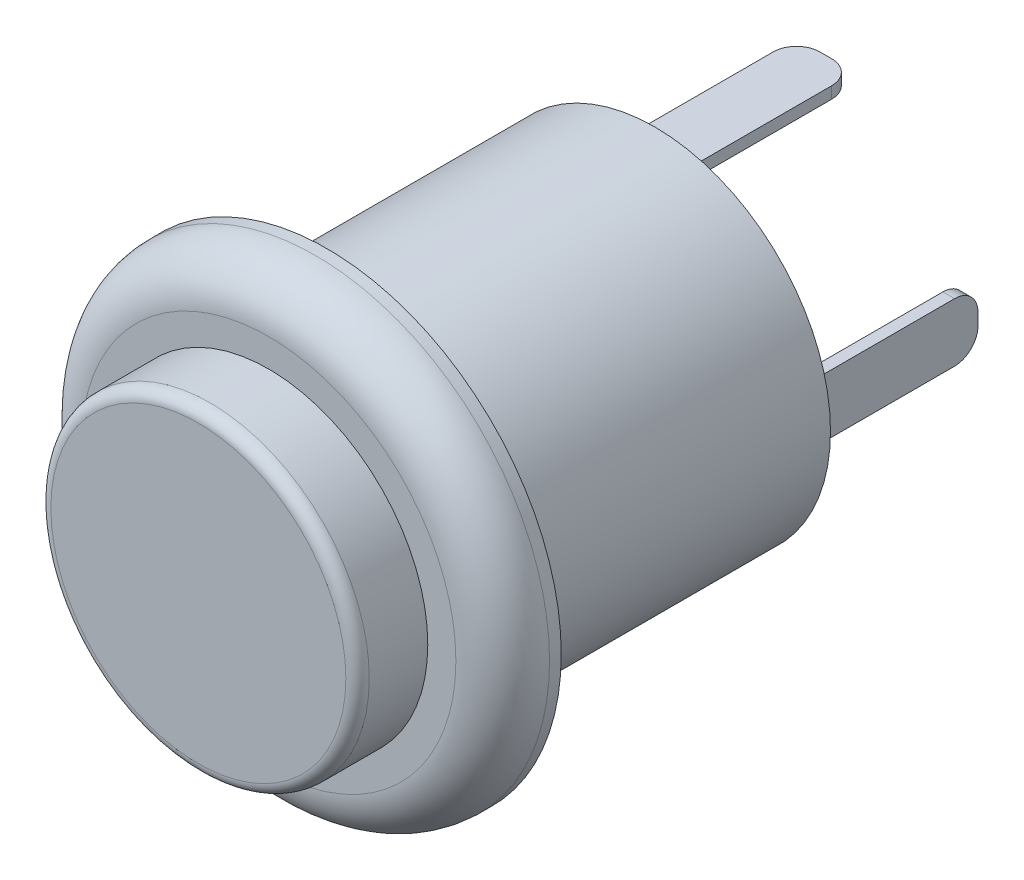
from build123d import *

# Parameters (mm, degrees)
SKETCH_1_R      = 7.5
EXTRUDE_1_DEPTH = 14
SKETCH_2_R      = 10
EXTRUDE_2_DEPTH = 2.5
SKETCH_3_R      = 6.8
EXTRUDE_3_DEPTH = 3
SKETCH_4_W      = 0.5
SKETCH_4_H      = 2.5
SKETCH_4_W_2    = 2.5
SKETCH_4_H_2    = 0.5
EXTRUDE_4_DEPTH = 7.3
FILLET_1_R      = 1
FILLET_2_R      = 0.5
FILLET_3_R      = 2


with BuildPart() as part:
    # ｽｹｯﾁ1 → ﾎﾞｽ - 押し出し1 (new body)
    with BuildSketch(Plane.XY):
        Circle(SKETCH_1_R)
    extrude(amount=EXTRUDE_1_DEPTH)

    # ｽｹｯﾁ2 → ﾎﾞｽ - 押し出し2 (add)
    with BuildSketch(Plane.XY.offset(14)):
        Circle(SKETCH_2_R)
    extrude(amount=EXTRUDE_2_DEPTH)

    # ｽｹｯﾁ3 → ﾎﾞｽ - 押し出し3 (add)
    with BuildSketch(Plane.XY.offset(16.5)):
        Circle(SKETCH_3_R)
    extrude(amount=EXTRUDE_3_DEPTH)

    # ｽｹｯﾁ4 → ﾎﾞｽ - 押し出し4 (add)
    with BuildSketch(Plane(origin=(0, 0, 0), x_dir=(-1, 0, 0), z_dir=(0, 0, -1))):
        with Locations((-6.25, 0)):
            Rectangle(SKETCH_4_W, SKETCH_4_H)
        with Locations((6.25, 0)):
            Rectangle(SKETCH_4_W, SKETCH_4_H)
        with Locations((0, 6.25)):
            Rectangle(SKETCH_4_W_2, SKETCH_4_H_2)
        with Locations((0, -6.25)):
            Rectangle(SKETCH_4_W_2, SKETCH_4_H_2)
    extrude(amount=EXTRUDE_4_DEPTH)

    # ﾌｨﾚｯﾄ1
    fillet_1_edges = [part.edges().sort_by_distance(p)[0] for p in [
        (6.25, 1.25, -7.3),
        (6.25, -1.25, -7.3),
        (-6.25, -1.25, -7.3),
        (-6.25, 1.25, -7.3),
        (-1.25, 6.25, -7.3),
        (1.25, 6.25, -7.3),
        (-1.25, -6.25, -7.3),
        (1.25, -6.25, -7.3),
    ]]
    fillet(fillet_1_edges, radius=FILLET_1_R)

    # ﾌｨﾚｯﾄ2
    fillet_2_edges = [part.edges().sort_by_distance(p)[0] for p in [
        (-6.8, 0, 19.5),
    ]]
    fillet(fillet_2_edges, radius=FILLET_2_R)

    # ﾌｨﾚｯﾄ3
    fillet_3_edges = [part.edges().sort_by_distance(p)[0] for p in [
        (-10, 0, 16.5),
    ]]
    fillet(fillet_3_edges, radius=FILLET_3_R)


solid = part.part
